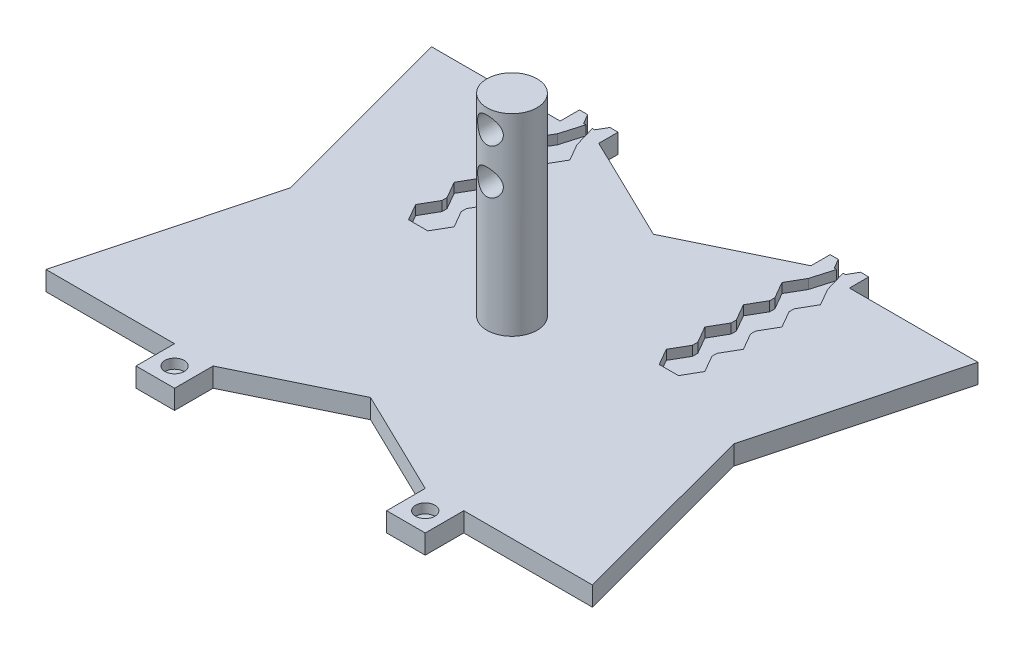
from build123d import *

# Parameters (mm, degrees)
CROQUIS1_R              = 0.5
SALIENTE_EXTRUIR1_DEPTH = 3
CROQUIS2_R              = 3.9
SALIENTE_EXTRUIR2_DEPTH = 30
CROQUIS3_R              = 2
CORTAR_EXTRUIR1_DEPTH   = 64
CROQUIS4_R              = 1.5
CORTAR_EXTRUIR2_DEPTH   = 1.5
CORTAR_EXTRUIR3_DEPTH   = 1.5


with BuildPart() as part:
    # Croquis1 → Saliente-Extruir1 (new body)
    with BuildSketch(Plane(origin=(0, 0, 0), x_dir=(1, 0, 0), z_dir=(0, 1, 0))):
        Polygon((30, 60), (30, 63), (31.267949192, 63), (32.133974596, 61.5), (33.866025404, 61.5), (34.732050808, 63), (36, 63), (36, 60), (52.5, 52), (69, 60), (69, 63), (70.267949192, 63), (71.133974596, 61.5), (72.866025404, 61.5), (73.732050808, 63), (75, 63), (75, 60), (95, 60), (87, 30), (95, 0), (75, 0), (75, -6), (69, -6), (69, 0), (52.5, 8), (36, 0), (36, -6), (30, -6), (30, 0), (10, 0), (18, 30), (10, 60), align=None)
        with Locations((33, -3)):
            Circle(CROQUIS1_R, mode=Mode.SUBTRACT)
        with Locations((72, -3)):
            Circle(CROQUIS1_R, mode=Mode.SUBTRACT)
    extrude(amount=SALIENTE_EXTRUIR1_DEPTH)

    # Croquis2 → Saliente-Extruir2 (add)
    with BuildSketch(Plane(origin=(0, 3, 0), x_dir=(1, 0, 0), z_dir=(0, 1, 0))):
        with Locations((52.5, 30)):
            Circle(CROQUIS2_R)
    extrude(amount=SALIENTE_EXTRUIR2_DEPTH)

    # Croquis3 → Cortar-Extruir1 (cut, through all)
    with BuildSketch(Plane.XY):
        with Locations((52.5, 30)):
            Circle(CROQUIS3_R)
        with Locations((52.5, 23)):
            Circle(CROQUIS3_R)
    extrude(amount=-CORTAR_EXTRUIR1_DEPTH, mode=Mode.SUBTRACT)

    # Croquis4 → Cortar-Extruir2 (cut)
    with BuildSketch(Plane(origin=(0, 3, 0), x_dir=(1, 0, 0), z_dir=(0, 1, 0))):
        with Locations((33, -3)):
            Circle(CROQUIS4_R)
        with Locations((72, -3)):
            Circle(CROQUIS4_R)
    extrude(amount=-CORTAR_EXTRUIR2_DEPTH, mode=Mode.SUBTRACT)

    # Croquis5 → Cortar-Extruir3 (cut)
    with BuildSketch(Plane(origin=(0, 3, 0), x_dir=(1, 0, 0), z_dir=(0, 1, 0))):
        Polygon((32.5, 61.5), (33.5, 61.5), (34.5, 58.098076211), (36, 55.5), (34.5, 52.901923789), (34.5, 52.098076211), (36, 49.5), (34.5, 46.901923789), (34.5, 46.098076211), (36, 43.5), (34.5, 40.901923789), (34.5, 40.098076211), (36, 37.5), (34.5, 34.901923789), (31.5, 34.901923789), (30, 37.5), (31.5, 40.098076211), (31.5, 40.901923789), (30, 43.5), (31.5, 46.098076211), (31.5, 46.901923789), (30, 49.5), (31.5, 52.098076211), (31.5, 52.901923789), (30, 55.5), (31.5, 58.098076211), align=None)
        Polygon((71.5, 61.5), (70.5, 58.098076211), (69, 55.5), (70.5, 52.901923789), (70.5, 52.098076211), (69, 49.5), (70.5, 46.901923789), (70.5, 46.098076211), (69, 43.5), (70.5, 40.901923789), (70.5, 40.098076211), (69, 37.5), (70.5, 34.901923789), (73.5, 34.901923789), (75, 37.5), (73.5, 40.098076211), (73.5, 40.901923789), (75, 43.5), (73.5, 46.098076211), (73.5, 46.901923789), (75, 49.5), (73.5, 52.098076211), (73.5, 52.901923789), (75, 55.5), (73.5, 58.098076211), (72.5, 61.5), align=None)
    extrude(amount=-CORTAR_EXTRUIR3_DEPTH, mode=Mode.SUBTRACT)


solid = part.part
